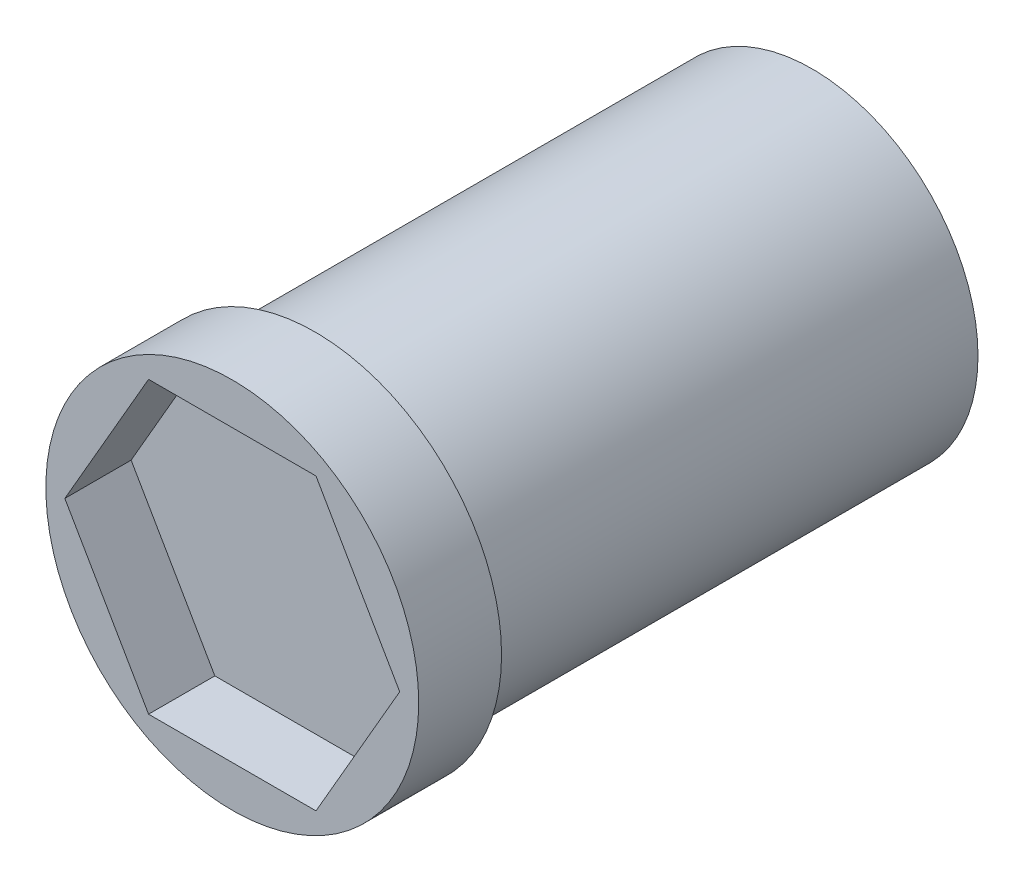
from build123d import *

# Parameters (mm, degrees)
SKETCH1_R           = 20
BOSS_EXTRUDE1_DEPTH = 60
SKETCH2_R           = 22.5
BOSS_EXTRUDE2_DEPTH = 10
CUT_EXTRUDE1_DEPTH  = 8


with BuildPart() as part:
    # Sketch1 → Boss-Extrude1 (new body)
    with BuildSketch(Plane.XY):
        Circle(SKETCH1_R)
    extrude(amount=BOSS_EXTRUDE1_DEPTH)

    # Sketch2 → Boss-Extrude2 (add)
    with BuildSketch(Plane.XY.offset(60)):
        Circle(SKETCH2_R)
    extrude(amount=BOSS_EXTRUDE2_DEPTH)

    # Sketch3 → Cut-Extrude1 (cut)
    with BuildSketch(Plane.XY.offset(70)):
        Polygon((-20.207259422, 0), (-10.103629711, -17.5), (10.103629711, -17.5), (20.207259422, 0), (10.103629711, 17.5), (-10.103629711, 17.5), align=None)
    extrude(amount=-CUT_EXTRUDE1_DEPTH, mode=Mode.SUBTRACT)


solid = part.part
